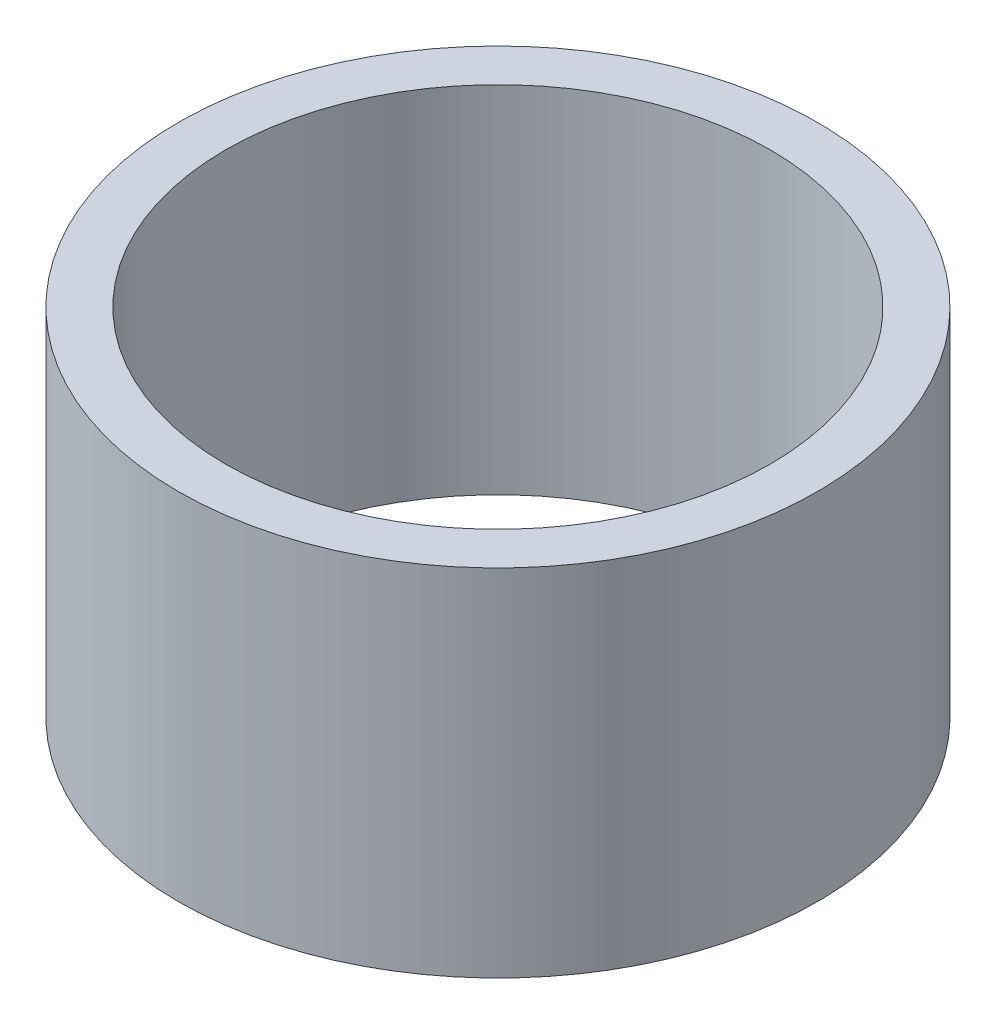
from build123d import *

# Parameters (mm, degrees)
SKETCH1_R           = 1.35
BOSS_EXTRUDE1_DEPTH = 1.5
SKETCH2_R           = 1.15
CUT_EXTRUDE1_DEPTH  = 2.5


with BuildPart() as part:
    # Sketch1 → Boss-Extrude1 (new body)
    with BuildSketch(Plane(origin=(0, 0, 0), x_dir=(1, 0, 0), z_dir=(0, 1, 0))):
        Circle(SKETCH1_R)
    extrude(amount=BOSS_EXTRUDE1_DEPTH)

    # Sketch2 → Cut-Extrude1 (cut, through all)
    with BuildSketch(Plane(origin=(0, 1.5, 0), x_dir=(1, 0, 0), z_dir=(0, 1, 0))):
        Circle(SKETCH2_R)
    extrude(amount=-CUT_EXTRUDE1_DEPTH, mode=Mode.SUBTRACT)


solid = part.part
